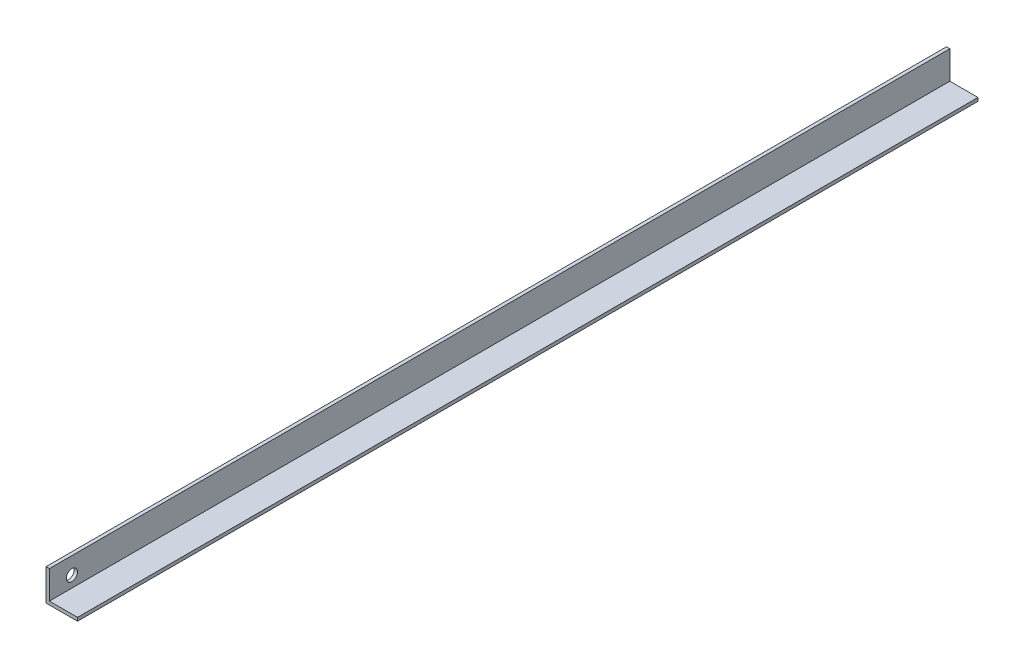
from build123d import *

# Parameters (mm, degrees)
EXTRUDE_1_DEPTH     = 800
SKETCH_2_R          = 5
CUT_EXTRUDE_3_DEPTH = 10


with BuildPart() as part:
    # Эскиз1 → Вытянуть-Тонкостенный1 (new body)
    with BuildSketch(Plane.XY):
        Polygon((0, 25), (0, 0), (25, 0), (25, -3), (-3, -3), (-3, 25), align=None)
    extrude(amount=EXTRUDE_1_DEPTH)

    # Эскиз2 → Вырез-Вытянуть3 (cut)
    with BuildSketch(Plane.YZ.offset(-3)):
        with Locations((10, 780)):
            Circle(SKETCH_2_R)
    extrude(amount=CUT_EXTRUDE_3_DEPTH, mode=Mode.SUBTRACT)


solid = part.part
